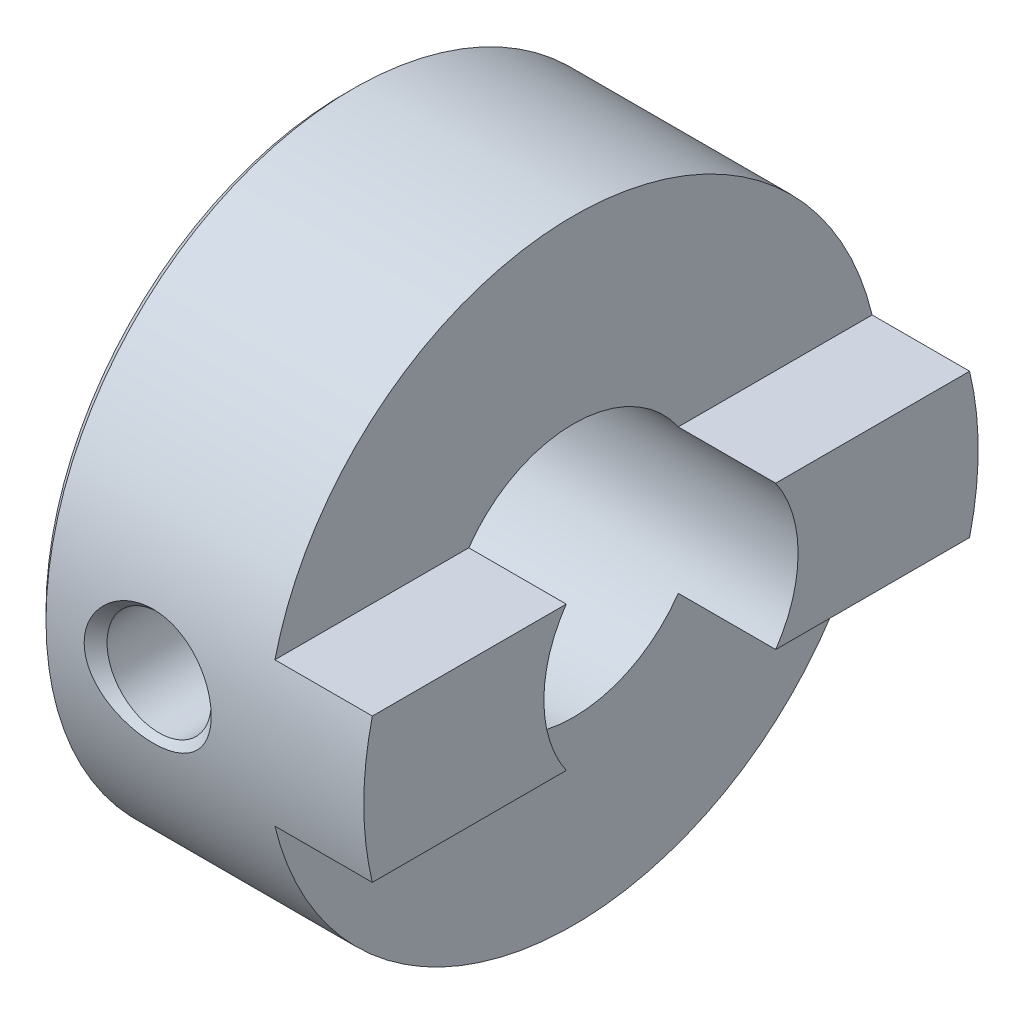
from build123d import *

# Parameters (mm, degrees)
SKETCH2_W          = 16.5
SKETCH2_H          = 15.5
SKETCH2_W_2        = 14.5
SKETCH2_H_2        = 3.4
CUT_EXTRUDE1_DEPTH = 2.3


with BuildPart() as part:
    # Sketch1 → Revolve1 (revolve)
    with BuildSketch(Plane.XY):
        Polygon((0, 7.05), (0, 3), (7.7, 3), (7.7, 7.25), (0.2, 7.25), align=None)
    revolve(axis=Axis((7.7, 0, 0), (-1, 0, 0)))

    # Sketch2 → Cut-Extrude1 (cut)
    with BuildSketch(Plane(origin=(7.7, 0, 0), x_dir=(0, 0, -1), z_dir=(1, 0, 0))):
        Rectangle(SKETCH2_W, SKETCH2_H)
        Rectangle(SKETCH2_W_2, SKETCH2_H_2, mode=Mode.SUBTRACT)
    extrude(amount=-CUT_EXTRUDE1_DEPTH, mode=Mode.SUBTRACT)

    # Sketch3 → Cut-Revolve1 (revolve, cut)
    with BuildSketch(Plane(origin=(2.6, 0, 0), x_dir=(0, 0, -1), z_dir=(1, 0, 0))):
        Polygon((-7.25, 0), (-7.25, 1.5), (-6.9795, 1.2295), (0, 1.2295), (0, 0), align=None)
    revolve(axis=Axis((2.6, 0, 0), (0, 0, 1)), mode=Mode.SUBTRACT)

    # Sketch4 → Cut-Revolve2 (revolve, cut)
    with BuildSketch(Plane(origin=(2.6, 0, 0), x_dir=(0, 0, -1), z_dir=(1, 0, 0))):
        Polygon((0, -7.25), (-1.5, -7.25), (-1.2295, -6.9795), (-1.2295, 0), (0, 0), align=None)
    revolve(axis=Axis((2.6, 0, 0), (0, -1, 0)), mode=Mode.SUBTRACT)


solid = part.part
